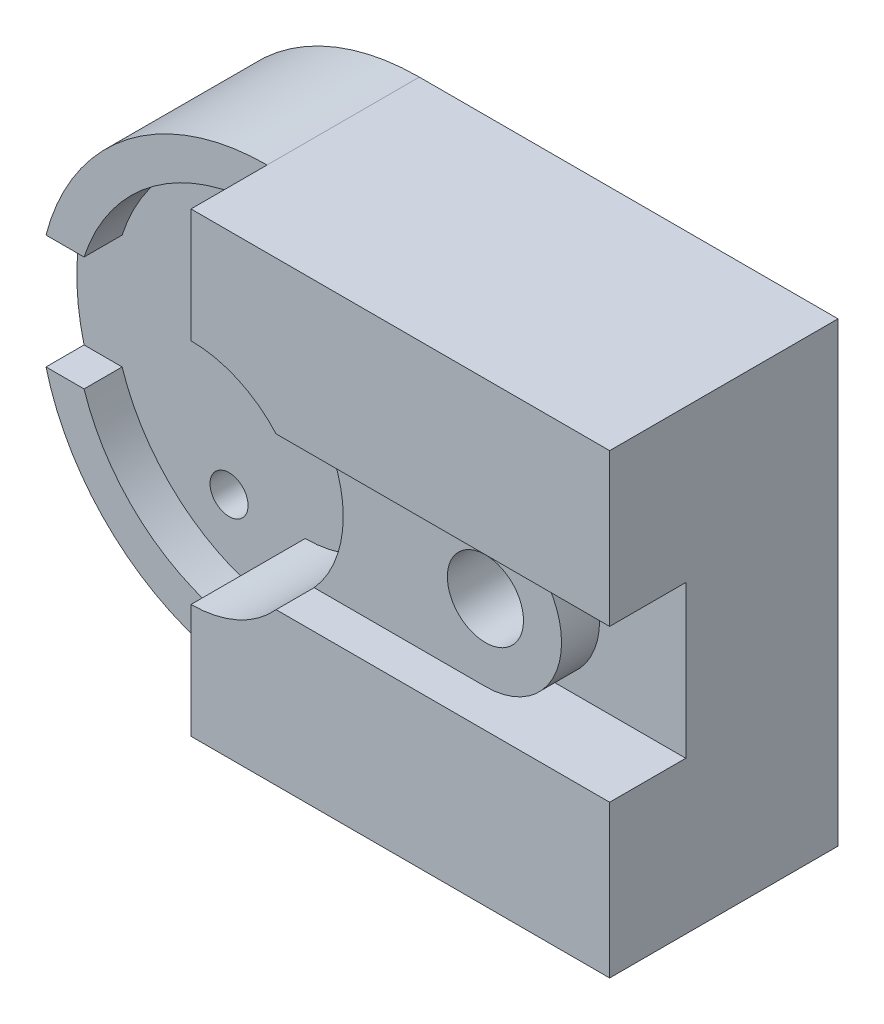
from build123d import *

# Parameters (mm, degrees)
BOSS_EXTRUDE4_DEPTH = 15
BOSS_EXTRUDE5_DEPTH = 5
BOSS_EXTRUDE8_DEPTH = 15
CUT_EXTRUDE2_DEPTH  = 10
BOSS_EXTRUDE9_DEPTH = 5
SKETCH11_R          = 5
CUT_EXTRUDE3_DEPTH  = 54
SKETCH12_R          = 5
SKETCH12_R_2        = 2.5
CUT_EXTRUDE4_DEPTH  = 76


with BuildPart() as part:
    # Sketch2 → Boss-Extrude4 (new body)
    with BuildSketch(Plane.XY):
        with BuildLine():
            Line((-55, 0), (0, 0))
            Line((0, 0), (0, 60))
            Line((0, 60), (-55, 60))
            ThreePointArc((-55, 60), (-85, 30), (-55, 0))
        make_face()
    extrude(amount=BOSS_EXTRUDE4_DEPTH)

    # Sketch5 → Boss-Extrude5 (add)
    with BuildSketch(Plane.XY.offset(15)):
        with BuildLine():
            Line((-84.047375097, 37.5), (-79.047375097, 37.5))
            ThreePointArc((-79.047375097, 37.5), (-69.870493007, 50.161897068), (-55, 55))
            Line((-55, 55), (-55, 60))
            ThreePointArc((-55, 60), (-73.371173071, 53.717082451), (-84.047375097, 37.5))
        make_face()
        with BuildLine():
            Line((-55, 0), (-55, 5))
            ThreePointArc((-55, 5), (-69.870493007, 9.838102932), (-79.047375097, 22.5))
            Line((-79.047375097, 22.5), (-84.047375097, 22.5))
            ThreePointArc((-84.047375097, 22.5), (-73.371173071, 6.282917549), (-55, 0))
        make_face()
    extrude(amount=BOSS_EXTRUDE5_DEPTH)

    # Sketch6 → Boss-Extrude8 (add)
    with BuildSketch(Plane.XY.offset(15)):
        with BuildLine():
            Line((-55, 60), (-55, 45))
            ThreePointArc((-55, 45), (-40, 30), (-55, 15))
            Line((-55, 15), (-55, 0))
            Line((-55, 0), (0, 0))
            Line((0, 0), (0, 60))
            Line((0, 60), (-55, 60))
        make_face()
    extrude(amount=BOSS_EXTRUDE8_DEPTH)

    # Sketch9 → Cut-Extrude2 (cut)
    with BuildSketch(Plane.XY.offset(30)):
        with BuildLine():
            Line((-43.819660113, 40), (0, 40))
            Line((0, 40), (0, 20))
            Line((0, 20), (-43.819660113, 20))
            ThreePointArc((-43.819660113, 20), (-40, 30), (-43.819660113, 40))
        make_face()
    extrude(amount=-CUT_EXTRUDE2_DEPTH, mode=Mode.SUBTRACT)

    # Sketch10 → Boss-Extrude9 (add)
    with BuildSketch(Plane.XY.offset(20)):
        with BuildLine():
            Line((-43.819660113, 40), (-21.319660113, 40))
            ThreePointArc((-21.319660113, 40), (-11.319660113, 30), (-21.319660113, 20))
            Line((-21.319660113, 20), (-43.819660113, 20))
            ThreePointArc((-43.819660113, 20), (-40, 30), (-43.819660113, 40))
        make_face()
    extrude(amount=BOSS_EXTRUDE9_DEPTH)

    # Sketch11 → Cut-Extrude3 (cut)
    with BuildSketch(Plane.XY.offset(25)):
        with Locations((-21.319660113, 30)):
            Circle(SKETCH11_R)
    extrude(amount=-CUT_EXTRUDE3_DEPTH, mode=Mode.SUBTRACT)

    # Sketch12 → Cut-Extrude4 (cut)
    with BuildSketch(Plane.XY.offset(15)):
        with Locations((-55, 30)):
            Circle(SKETCH12_R)
        with Locations((-65, 15)):
            Circle(SKETCH12_R_2)
        with Locations((-65, 45)):
            Circle(SKETCH12_R_2)
    extrude(amount=-CUT_EXTRUDE4_DEPTH, mode=Mode.SUBTRACT)


solid = part.part
